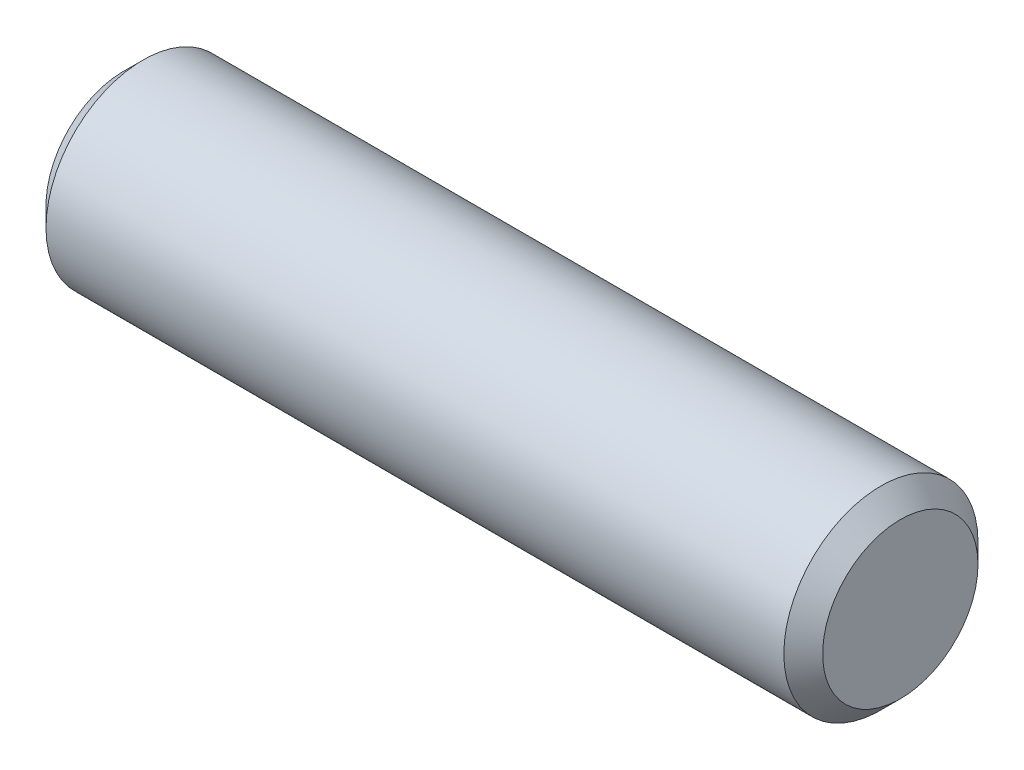
from build123d import *

# Parameters (mm, degrees)
SKETCH2_R           = 0.79375
EXTRUDE1_DEPTH      = 3.175
EXTRUDE1_DEPTH_BACK = 3.175
CHAMFER1_SIZE       = 0.15875


with BuildPart() as part:
    # Sketch2 → Extrude1 (new body, two sides)
    with BuildSketch(Plane(origin=(0, 0, 0), x_dir=(0, 0, -1), z_dir=(1, 0, 0))) as extrude1_sk:
        Circle(SKETCH2_R)
    extrude(amount=EXTRUDE1_DEPTH)
    extrude(extrude1_sk.sketch, amount=-EXTRUDE1_DEPTH_BACK)

    # Chamfer1
    chamfer1_edges = [part.edges().sort_by_distance(p)[0] for p in [
        (-3.175, 0, 0.79375),
        (3.175, 0, 0.79375),
    ]]
    chamfer(chamfer1_edges, length=CHAMFER1_SIZE)


solid = part.part
